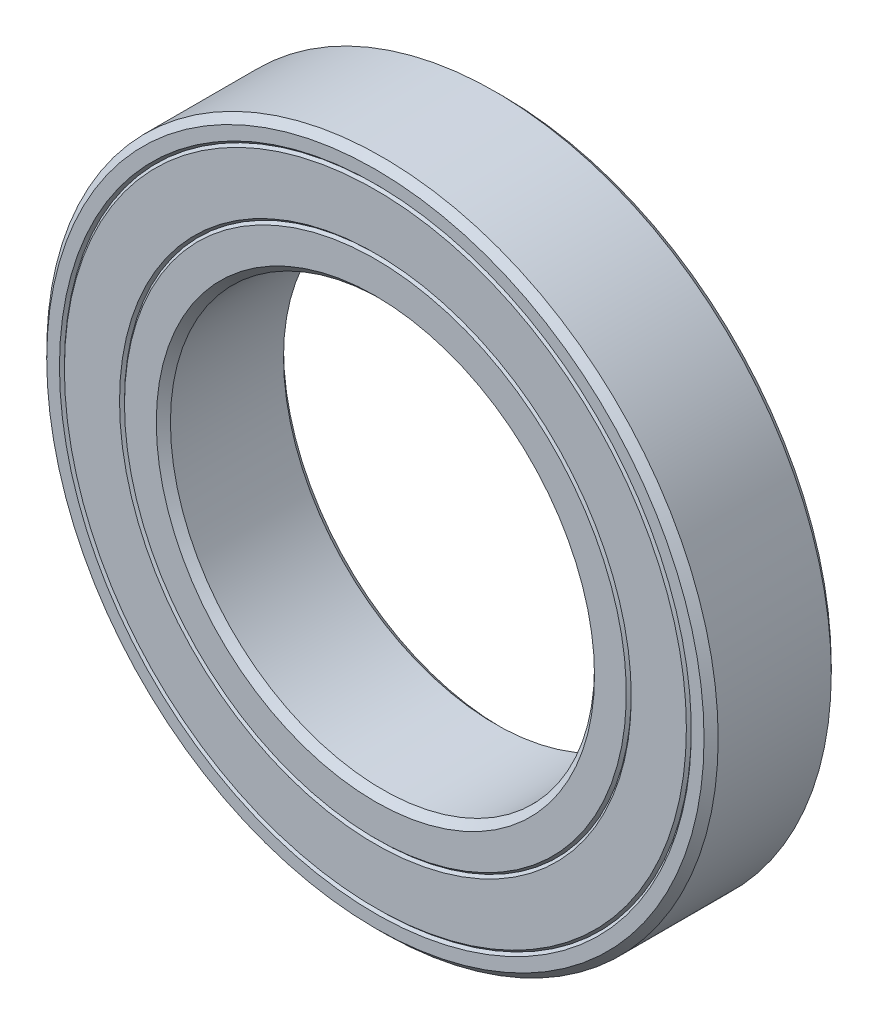
from build123d import *

# Parameters (mm, degrees)
SKETCH1_R      = 47.5
SKETCH1_R_2    = 30
EXTRUDE1_DEPTH = 18
CHAMFER1_SIZE  = 1


with BuildPart() as part:
    # Sketch1 → Extrude1 (new body)
    with BuildSketch(Plane.XY):
        Circle(SKETCH1_R)
        Circle(SKETCH1_R_2, mode=Mode.SUBTRACT)
    extrude(amount=EXTRUDE1_DEPTH)

    # Chamfer1
    chamfer1_edges = [part.edges().sort_by_distance(p)[0] for p in [
        (-47.5, 0, 0),
        (-47.5, 0, 18),
        (-30, 0, 0),
        (-30, 0, 18),
    ]]
    chamfer(chamfer1_edges, length=CHAMFER1_SIZE)

    # Sketch2 → Cut-Revolve1 (revolve, cut)
    with BuildSketch(Plane(origin=(0, 0, 0), x_dir=(0, 0, -1), z_dir=(1, 0, 0))):
        Polygon((-18, 35.5), (-17.65, 35.85), (-18, 36.2), align=None)
        Polygon((-17.65, 44.35), (-18, 44), (-18, 44.7), align=None)
        Polygon((0, 35.5), (0, 36.2), (-0.35, 35.85), align=None)
        Polygon((0, 44.7), (0, 44), (-0.35, 44.35), align=None)
    revolve(axis=Axis((0, 0, 0), (0, 0, 1)), mode=Mode.SUBTRACT)


solid = part.part
